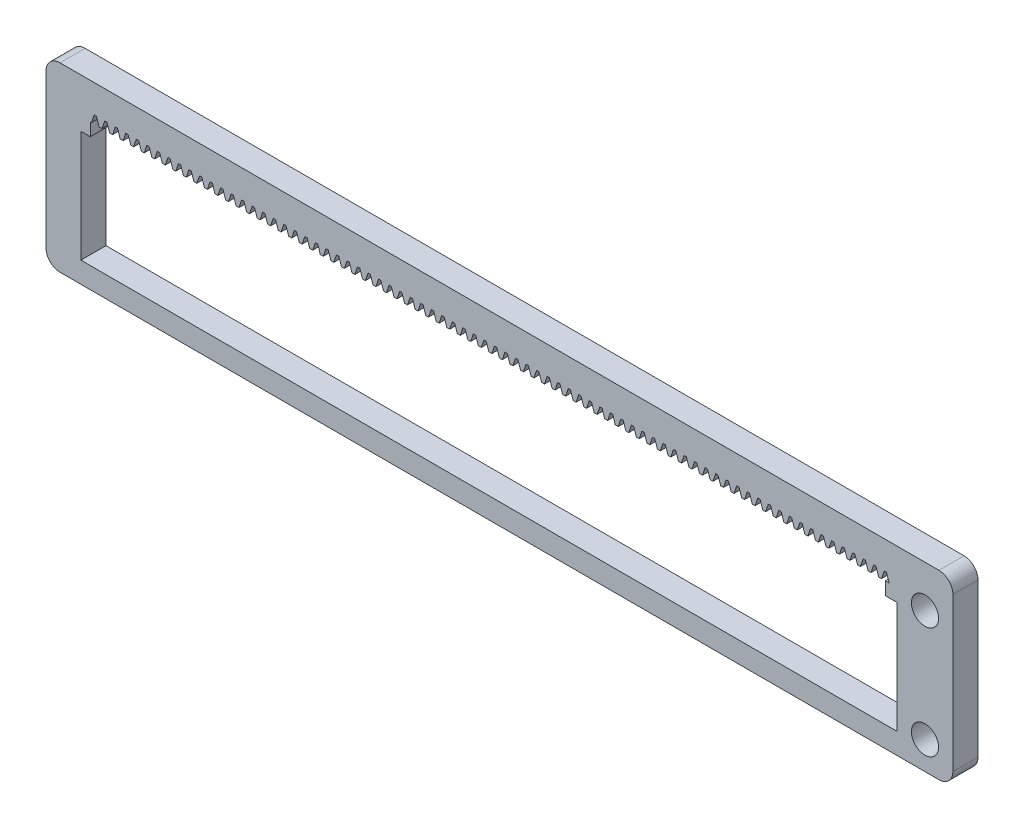
from build123d import *

# Parameters (mm, degrees)
BOSS_EXTRUDE1_DEPTH = 3.6
SKETCH2_W           = 117
SKETCH2_H           = 16
CUT_EXTRUDE1_DEPTH  = 3.6
SKETCH3_W           = 113.97
SKETCH3_H           = 1.85
CUT_EXTRUDE2_DEPTH  = 3.6
CUT_EXTRUDE4_DEPTH  = 3.6
LPATTERN1_COUNT     = 76
LPATTERN1_PITCH     = 1.51
SKETCH5_R           = 1.95
CUT_EXTRUDE5_DEPTH  = 10


with BuildPart() as part:
    # Sketch1 → Boss-Extrude1 (new body)
    with BuildSketch(Plane.XY):
        with BuildLine():
            Line((2, 0), (128, 0))
            ThreePointArc((128, 0), (129.414213562, -0.585786438), (130, -2))
            Line((130, -2), (130, -24))
            ThreePointArc((130, -24), (129.414213562, -25.414213562), (128, -26))
            Line((128, -26), (2, -26))
            ThreePointArc((2, -26), (0.585786438, -25.414213562), (0, -24))
            Line((0, -24), (0, -2))
            ThreePointArc((0, -2), (0.585786438, -0.585786438), (2, 0))
        make_face()
    extrude(amount=BOSS_EXTRUDE1_DEPTH)

    # Sketch2 → Cut-Extrude1 (cut)
    with BuildSketch(Plane.XY.offset(3.6)):
        with Locations((63.5, -15)):
            Rectangle(SKETCH2_W, SKETCH2_H)
    extrude(amount=-CUT_EXTRUDE1_DEPTH, mode=Mode.SUBTRACT)

    # Sketch3 → Cut-Extrude2 (cut)
    with BuildSketch(Plane.XY.offset(3.6)):
        with Locations((63.335, -6.075)):
            Rectangle(SKETCH3_W, SKETCH3_H)
    extrude(amount=-CUT_EXTRUDE2_DEPTH, mode=Mode.SUBTRACT)

    # Sketch4 → Cut-Extrude4 (cut)
    with BuildSketch(Plane.XY.offset(3.6)):
        Polygon((120.485, -4.011755738), (120.865, -5.15), (119.775, -5.15), (120.155, -4.011755738), align=None)
    cut_extrude4 = extrude(amount=-CUT_EXTRUDE4_DEPTH, mode=Mode.SUBTRACT)

    # LPattern1: Cut-Extrude4 ×76
    with Locations(*[(-i * LPATTERN1_PITCH, 0, 0) for i in range(1, LPATTERN1_COUNT)]):
        add(cut_extrude4, mode=Mode.SUBTRACT)

    # Sketch5 → Cut-Extrude5 (cut)
    with BuildSketch(Plane.XY.offset(3.6)):
        with Locations((126, -6)):
            Circle(SKETCH5_R)
        with Locations((126, -22)):
            Circle(SKETCH5_R)
    extrude(amount=-CUT_EXTRUDE5_DEPTH, mode=Mode.SUBTRACT)


solid = part.part
